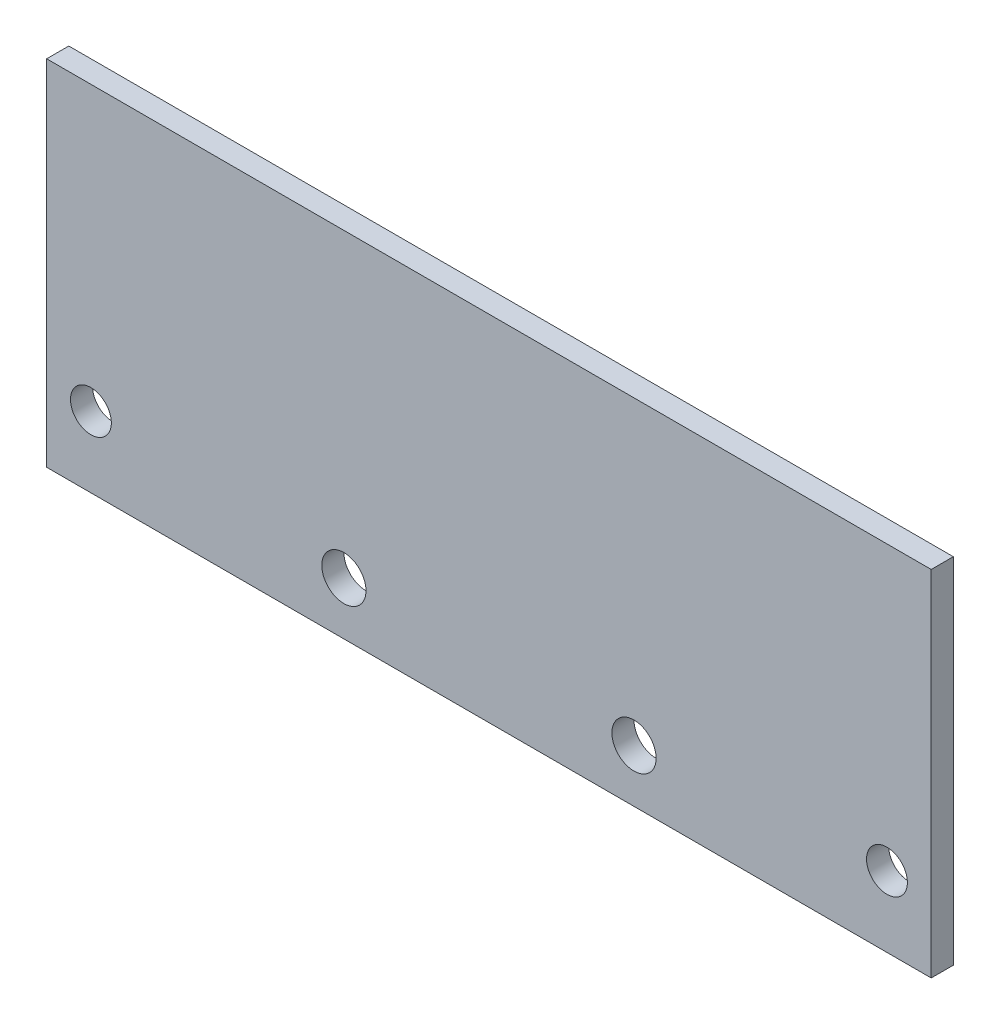
from build123d import *

# Parameters (mm, degrees)
SKETCH1_W           = 127
SKETCH1_H           = 50.8
BOSS_EXTRUDE1_DEPTH = 3.175
SKETCH2_R           = 2.9337
SKETCH2_R_2         = 3.175
CUT_EXTRUDE1_DEPTH  = 4.175


with BuildPart() as part:
    # Sketch1 → Boss-Extrude1 (new body)
    with BuildSketch(Plane.XY):
        with Locations((0, 25.4)):
            Rectangle(SKETCH1_W, SKETCH1_H)
    extrude(amount=BOSS_EXTRUDE1_DEPTH)

    # Sketch2 → Cut-Extrude1 (cut, through all)
    with BuildSketch(Plane(origin=(0, 0, 0), x_dir=(-1, 0, 0), z_dir=(0, 0, -1))):
        with Locations((-57.15, 10.16)):
            Circle(SKETCH2_R)
        with Locations((57.15, 10.16)):
            Circle(SKETCH2_R)
        with Locations((20.828, 7.567424528)):
            Circle(SKETCH2_R_2)
        with Locations((-20.828, 7.567424528)):
            Circle(SKETCH2_R_2)
    extrude(amount=-CUT_EXTRUDE1_DEPTH, mode=Mode.SUBTRACT)


solid = part.part
